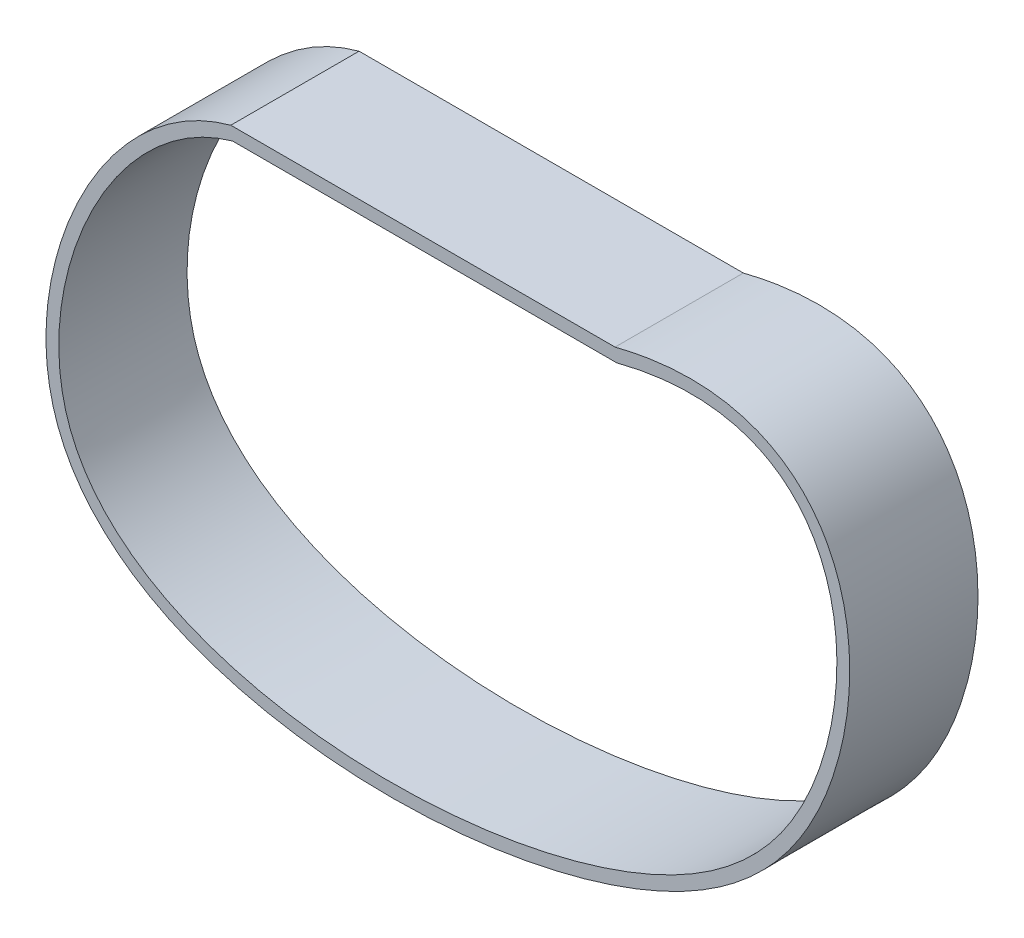
from build123d import *

# Parameters (mm, degrees)
BOSS_EXTRUDE1_DEPTH = 10


with BuildPart() as part:
    # Sketch1 → Boss-Extrude1 (new body, symmetric)
    with BuildSketch(Plane.XY):
        with BuildLine():
            Line((-29.109488938, 2), (30.806019374, 2))
            add(Edge.make_bspline(
                [(30.806019374, 2), (31.339005391, 2.13589874), (32.420285659, 2.39664087), (34.502023546, 2.838658031), (37.019447608, 3.261004871), (39.887533308, 3.560639976), (43.519128896, 3.693738515), (47.700836797, 3.373944758), (52.157359772, 2.256288216), (56.044035485, 0.455274826), (60.444334505, -2.763904799), (64.442297521, -8.086729155), (67.012750653, -15.78971807), (67.668343918, -24.238230618), (66.652434223, -32.950277254), (64.162524345, -41.448894606), (60.360062445, -49.246462696), (55.395640775, -55.864053474), (49.372938514, -61.385143133), (42.397299201, -65.897910229), (34.569189201, -69.513718914), (23.072251511, -73.320523974), (7.140831425, -76.238142585), (-12.571253539, -76.531233106), (-31.017229704, -73.329970509), (-43.807972088, -67.432043748), (-51.496493039, -60.468967394), (-55.683262495, -54.063466146), (-57.884892933, -46.455382485), (-58.10101488, -38.14720342), (-56.623689052, -29.57026659), (-52.617447299, -18.327017856), (-45.890452943, -8.213436103), (-38.059201908, -1.909827174), (-33.708577362, 0.38036745), (-31.426231137, 1.281380833), (-30.26953148, 1.663956301), (-29.588436418, 1.867390986), (-29.271166606, 1.954932691), (-29.109488938, 2)],
                knots=[0.000597945, 0.000597945, 0.000597945, 0.000597945, 0.004506152, 0.008414359, 0.016230774, 0.024047188, 0.031863602, 0.047496431, 0.06312926, 0.078762089, 0.094394918, 0.125660575, 0.156926233, 0.188191891, 0.219457548, 0.250723206, 0.281988864, 0.313254521, 0.344520179, 0.375785837, 0.407051494, 0.438317152, 0.500848467, 0.563379783, 0.625911098, 0.688442413, 0.719708071, 0.750973729, 0.782239386, 0.813505044, 0.844770702, 0.876036359, 0.938567675, 0.969833332, 0.985466161, 0.993282576, 0.997190783, 0.999144886, 1.00109899, 1.00109899, 1.00109899, 1.00109899], degree=3))
        make_face()
        with BuildLine():
            Line((-28.835955081, 0), (31.058979205, 0))
            add(Edge.make_bspline(
                [(31.058979205, 0), (68.495483915, 9.703365158), (72.225474707, -44.302023431), (19.353809106, -80.691988602), (-78.423863055, -73.429422761), (-47.708464205, -5.260672109), (-28.835955081, 0)],
                knots=[0, 0, 0, 0, 0.277880774, 0.417213322, 0.76385294, 1, 1, 1, 1], degree=3))
        make_face(mode=Mode.SUBTRACT)
    extrude(amount=BOSS_EXTRUDE1_DEPTH, both=True)


solid = part.part
